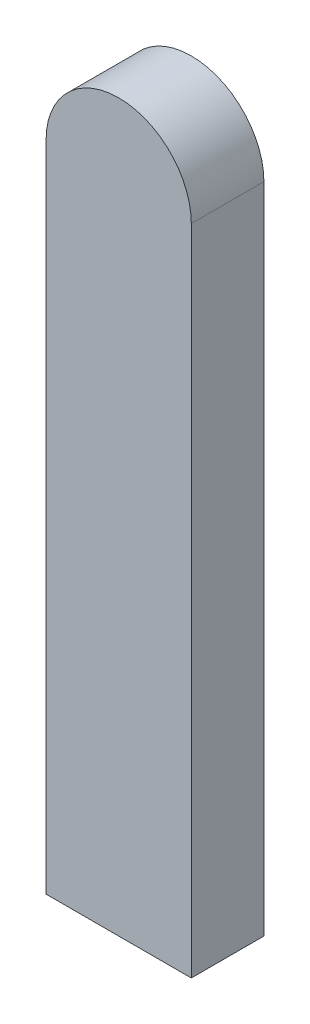
from build123d import *

# Parameters (mm, degrees)
BOSS_EXTRUDE1_DEPTH = 10


with BuildPart() as part:
    # Sketch1 → Boss-Extrude1 (new body)
    with BuildSketch(Plane.XY):
        with BuildLine():
            Line((-10, 45), (-10, -45))
            Line((-10, -45), (10, -45))
            Line((10, -45), (10, 45))
            ThreePointArc((10, 45), (0, 55), (-10, 45))
        make_face()
    extrude(amount=BOSS_EXTRUDE1_DEPTH)


solid = part.part
